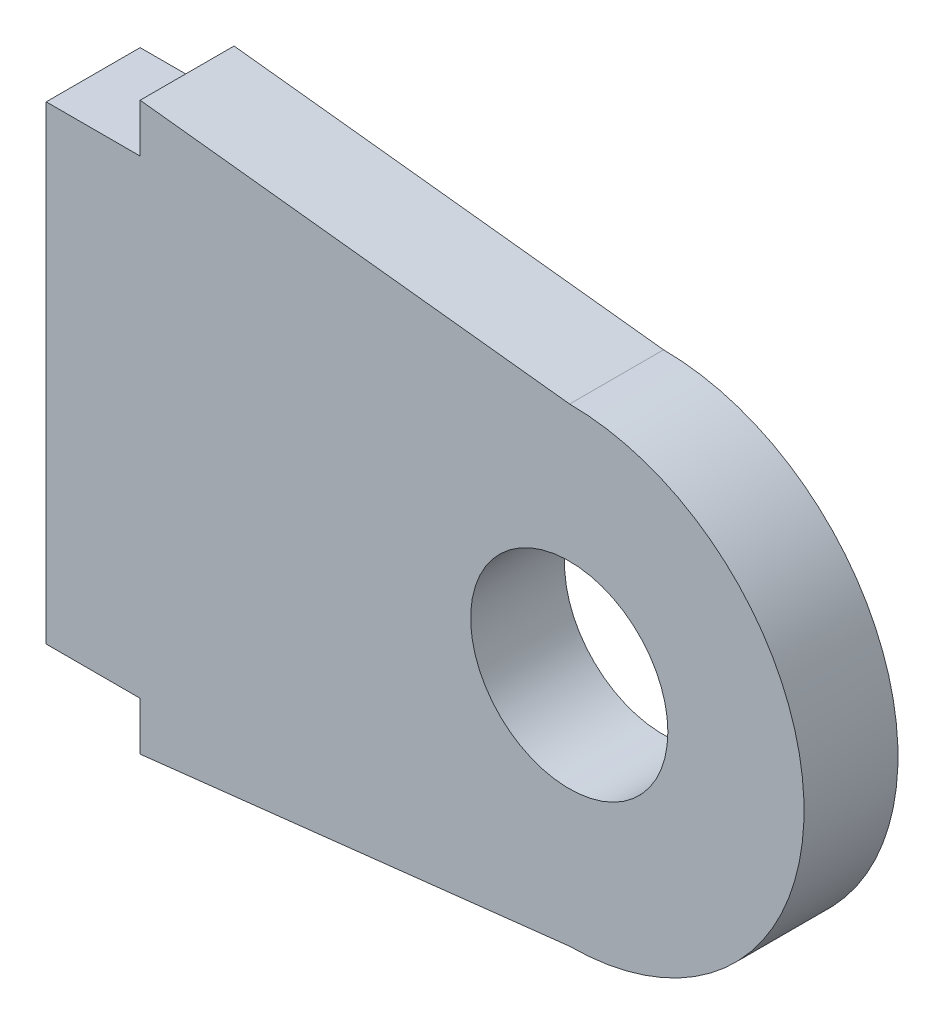
from build123d import *

# Parameters (mm, degrees)
CROQUIS1_R              = 4.2
SALIENTE_EXTRUIR1_DEPTH = 4


with BuildPart() as part:
    # Croquis1 → Saliente-Extruir1 (new body)
    with BuildSketch(Plane.XY):
        with BuildLine():
            Line((2, 14.378089444), (-2, 14.378089444))
            Line((-2, 14.378089444), (-2, -5.621910556))
            Line((-2, -5.621910556), (2, -5.621910556))
            Line((2, -5.621910556), (2, -7.681185842))
            Line((2, -7.681185842), (20.292265124, -5.621910556))
            ThreePointArc((20.292265124, -5.621910556), (30.276145575, 4.378089444), (20.292265124, 14.378089444))
            Line((20.292265124, 14.378089444), (2, 16.43736473))
            Line((2, 16.43736473), (2, 14.378089444))
        make_face()
        with Locations((20.276132562, 4.378089444)):
            Circle(CROQUIS1_R, mode=Mode.SUBTRACT)
    extrude(amount=SALIENTE_EXTRUIR1_DEPTH)


solid = part.part
